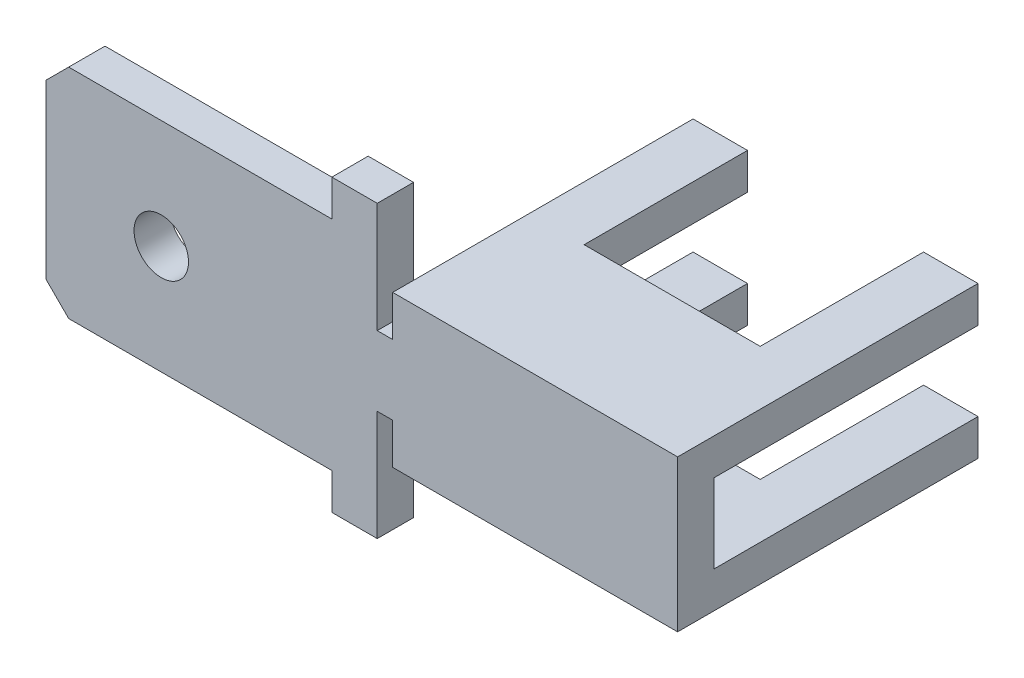
from build123d import *

# Parameters (mm, degrees)
SKETCH1_R           = 0.6
BOSS_EXTRUDE1_DEPTH = 6.62
SKETCH2_W           = 5.82
SKETCH2_H           = 1.74
SKETCH2_H_2         = 1.53
CUT_EXTRUDE1_DEPTH  = 16.742642726
SKETCH5_W           = 0.8
SKETCH5_H           = 1.53
CUT_EXTRUDE4_DEPTH  = 6.62
SKETCH4_W           = 7.64
SKETCH4_H           = 5.82
SKETCH4_W_2         = 3.88
SKETCH4_H_2         = 3.6
CUT_EXTRUDE3_DEPTH  = 15.638606491
CHAMFER1_SIZE       = 0.5
SKETCH11_W          = 0.34
SKETCH11_H          = 0.8
CUT_EXTRUDE5_DEPTH  = 0.9


with BuildPart() as part:
    # Sketch1 → Boss-Extrude1 (new body)
    with BuildSketch(Plane.XY):
        Polygon((3.76, 2.4), (3.76, 3.2), (11.38, 3.2), (11.38, -3.2), (3.76, -3.2), (3.76, -2.4), (-2.54, -2.4), (-2.54, 2.4), align=None)
        Circle(SKETCH1_R, mode=Mode.SUBTRACT)
    extrude(amount=BOSS_EXTRUDE1_DEPTH)

    # Sketch2 → Cut-Extrude1 (cut, through all)
    with BuildSketch(Plane(origin=(11.38, 0, 0), x_dir=(0, 0, -1), z_dir=(1, 0, 0))):
        with Locations((-2.91, 0)):
            Rectangle(SKETCH2_W, SKETCH2_H)
        with Locations((-2.91, 2.435)):
            Rectangle(SKETCH2_W, SKETCH2_H_2)
        with Locations((-2.91, -2.435)):
            Rectangle(SKETCH2_W, SKETCH2_H_2)
    extrude(amount=-CUT_EXTRUDE1_DEPTH, mode=Mode.SUBTRACT)

    # Sketch5 → Cut-Extrude4 (cut)
    with BuildSketch(Plane(origin=(11.38, 0, 0), x_dir=(0, 0, -1), z_dir=(1, 0, 0))):
        with Locations((-6.22, 2.435)):
            Rectangle(SKETCH5_W, SKETCH5_H)
        with Locations((-6.22, -2.435)):
            Rectangle(SKETCH5_W, SKETCH5_H)
    extrude(amount=-CUT_EXTRUDE4_DEPTH, mode=Mode.SUBTRACT)

    # Sketch4 → Cut-Extrude3 (cut, through all)
    with BuildSketch(Plane.XZ.offset(3.2)):
        with Locations((1.28, 2.91)):
            Rectangle(SKETCH4_W, SKETCH4_H)
        with Locations((8.24, 1.8)):
            Rectangle(SKETCH4_W_2, SKETCH4_H_2)
    extrude(amount=-CUT_EXTRUDE3_DEPTH, mode=Mode.SUBTRACT)

    # Chamfer1
    chamfer1_edges = [part.edges().sort_by_distance(p)[0] for p in [
        (-2.54, 2.4, 6.22),
        (-2.54, -2.4, 6.22),
    ]]
    chamfer(chamfer1_edges, length=CHAMFER1_SIZE)

    # Sketch11 → Cut-Extrude5 (cut)
    with BuildSketch(Plane.XZ.offset(1.67)):
        with Locations((4.93, 6.22)):
            Rectangle(SKETCH11_W, SKETCH11_H)
    cut_extrude5 = extrude(amount=-CUT_EXTRUDE5_DEPTH, mode=Mode.SUBTRACT)

    # Mirror1: Cut-Extrude5 across plane
    add(cut_extrude5.mirror(Plane.ZX), mode=Mode.SUBTRACT)


solid = part.part
